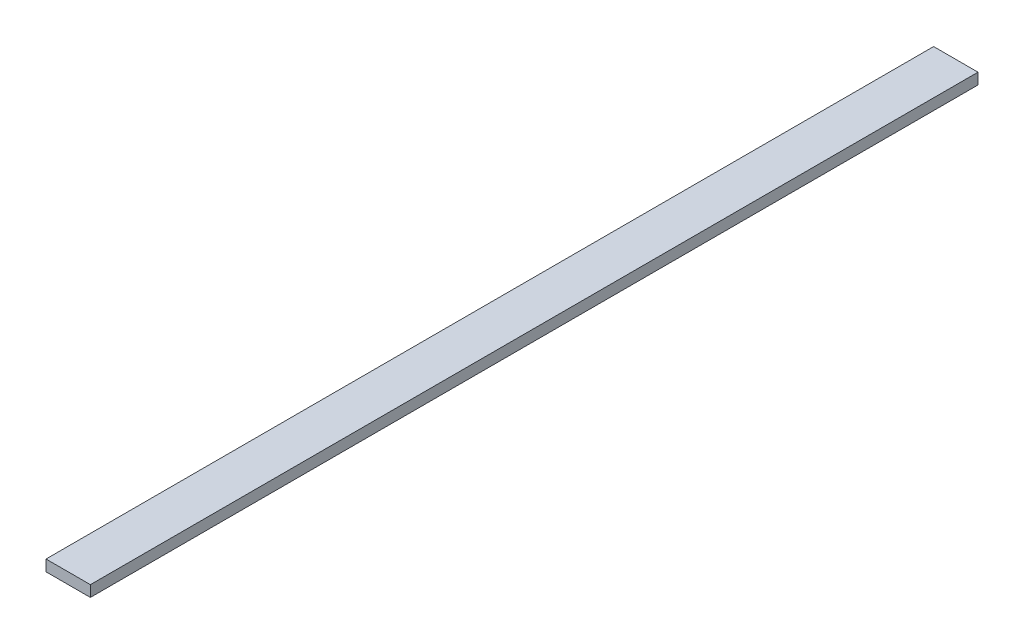
from build123d import *

# Parameters (mm, degrees)
SKETCH1_W           = 500
SKETCH1_H           = 10000
BOSS_EXTRUDE1_DEPTH = 125


with BuildPart() as part:
    # Sketch1 → Boss-Extrude1 (new body)
    with BuildSketch(Plane(origin=(0, 0, 0), x_dir=(1, 0, 0), z_dir=(0, 1, 0))):
        with Locations((228.206187031, 4954.836917703)):
            Rectangle(SKETCH1_W, SKETCH1_H)
    extrude(amount=BOSS_EXTRUDE1_DEPTH)


solid = part.part
